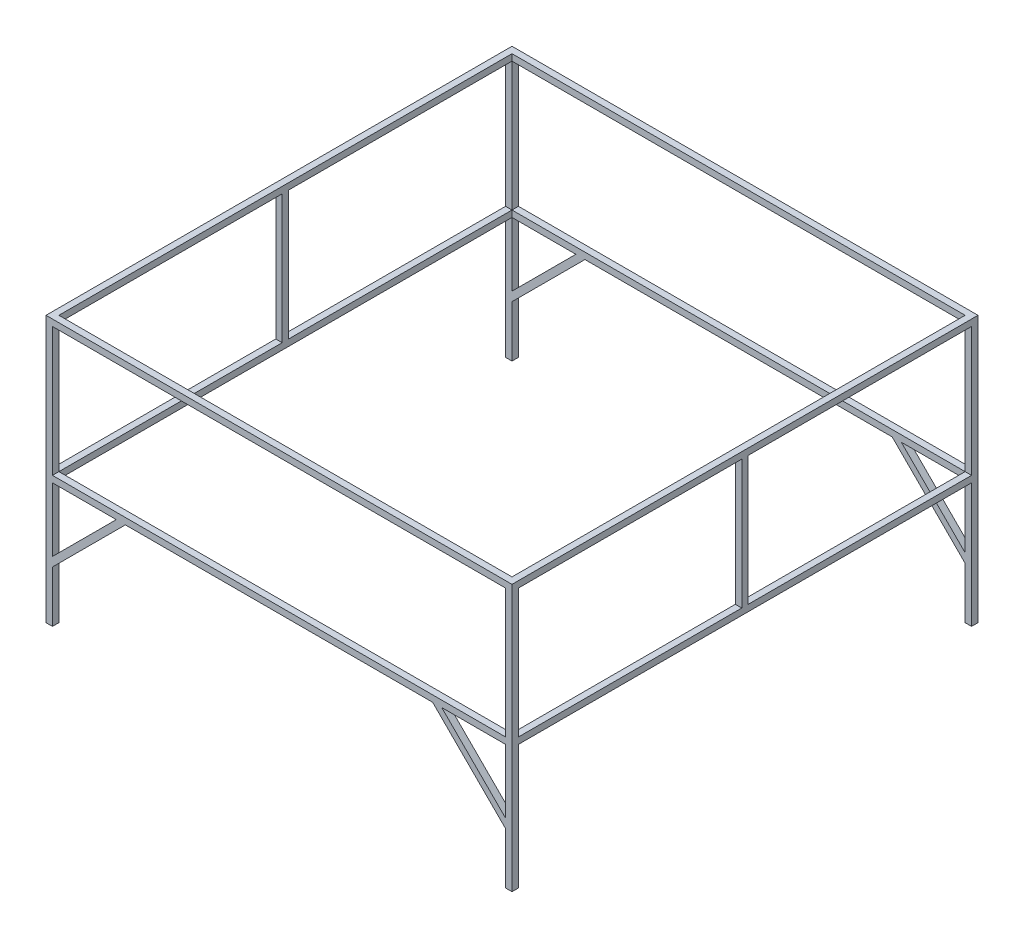
from build123d import *

# Parameters (mm, degrees)
SKETCH1_W                                = 1150
SKETCH1_H                                = 1150
SKETCH1_W_2                              = 1118.25
SKETCH1_H_2                              = 1118.25
BOSS_EXTRUDE1_DEPTH                      = 15.875
SKETCH2_W                                = 15.875
SKETCH2_H                                = 15.875
BOSS_EXTRUDE2_DEPTH                      = 318.25
SKETCH3_W                                = 1150
SKETCH3_H                                = 1150
SKETCH3_W_2                              = 1118.25
SKETCH3_H_2                              = 1118.25
BOSS_EXTRUDE3_DEPTH                      = 15.875
BOSS_EXTRUDE4_DEPTH                      = 15.875
MIRROR2_AT_THE_SECOND_PLANE_COPY_1_DEPTH = 15.875


with BuildPart() as part:
    # Sketch1 → Boss-Extrude1 (new body)
    with BuildSketch(Plane(origin=(0, 0, 0), x_dir=(1, 0, 0), z_dir=(0, 1, 0))):
        Rectangle(SKETCH1_W, SKETCH1_H)
        Rectangle(SKETCH1_W_2, SKETCH1_H_2, mode=Mode.SUBTRACT)
    extrude(amount=BOSS_EXTRUDE1_DEPTH)

    # Sketch2 → Boss-Extrude2 (add)
    with BuildSketch(Plane(origin=(0, 15.875, 0), x_dir=(1, 0, 0), z_dir=(0, 1, 0))):
        with Locations((-567.0625, 567.0625)):
            Rectangle(SKETCH2_W, SKETCH2_H)
        with Locations((-567.0625, -567.0625)):
            Rectangle(SKETCH2_W, SKETCH2_H)
        with Locations((-567.0625, 0)):
            Rectangle(SKETCH2_W, SKETCH2_H)
    boss_extrude2 = extrude(amount=BOSS_EXTRUDE2_DEPTH)

    # Sketch3 → Boss-Extrude3 (add)
    with BuildSketch(Plane(origin=(0, 334.125, 0), x_dir=(1, 0, 0), z_dir=(0, 1, 0))):
        Rectangle(SKETCH3_W, SKETCH3_H)
        Rectangle(SKETCH3_W_2, SKETCH3_H_2, mode=Mode.SUBTRACT)
    extrude(amount=BOSS_EXTRUDE3_DEPTH)

    # Mirror1: Boss-Extrude2 across plane
    add(boss_extrude2.mirror(Plane(origin=(0, 0, 0), x_dir=(0, 0, 1), z_dir=(1, 0, 0))))

    # Sketch4 → Boss-Extrude4 (add)
    with BuildSketch(Plane.XY.offset(575)):
        Polygon((390.350320151, 11.225320151), (379.125, 0), (559.125, -180), (559.125, -307), (575, -307), (575, 0), (559.125, 0), (559.125, -157.549359697), align=None)
    boss_extrude4 = extrude(amount=-BOSS_EXTRUDE4_DEPTH)

    # Mirror2: Boss-Extrude4 across plane
    add(boss_extrude4.mirror(Plane(origin=(0, 0, 0), x_dir=(0, 0, 1), z_dir=(1, 0, 0))))

    # Mirror2 at the second plane: Boss-Extrude4 across plane
    add(boss_extrude4.mirror(Plane.XY))

    # Mirror2 at the second plane copy 1 sketc → Mirror2 at the second plane copy 1 (add)
    with BuildSketch(Plane(origin=(0, 0, -575), x_dir=(-1, 0, 0), z_dir=(0, 0, -1))):
        Polygon((390.350320151, 11.225320151), (379.125, 0), (559.125, -180), (559.125, -307), (575, -307), (575, 0), (559.125, 0), (559.125, -157.549359697), align=None)
    extrude(amount=-MIRROR2_AT_THE_SECOND_PLANE_COPY_1_DEPTH)


solid = part.part
